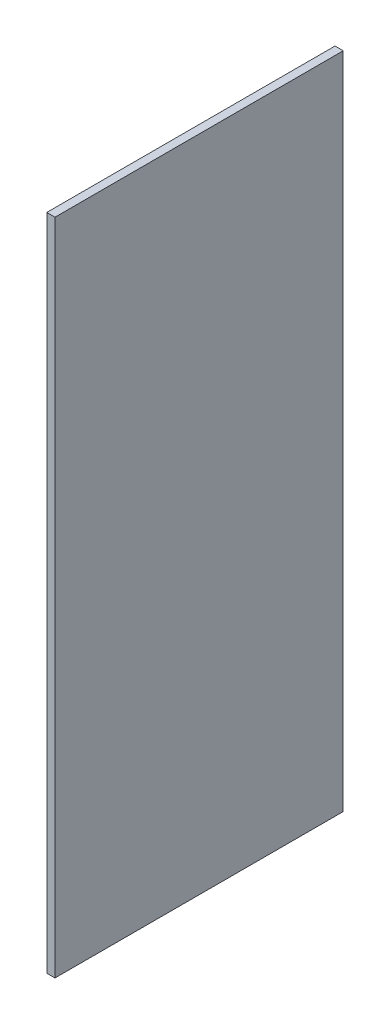
from build123d import *

# Parameters (mm, degrees)
SKETCH1_W           = 88.9
SKETCH1_H           = 203.2
BOSS_EXTRUDE1_DEPTH = 2.54


with BuildPart() as part:
    # Sketch1 → Boss-Extrude1 (new body)
    with BuildSketch(Plane(origin=(0, 0, 0), x_dir=(0, 0, -1), z_dir=(1, 0, 0))):
        Rectangle(SKETCH1_W, SKETCH1_H)
    extrude(amount=BOSS_EXTRUDE1_DEPTH)


solid = part.part
